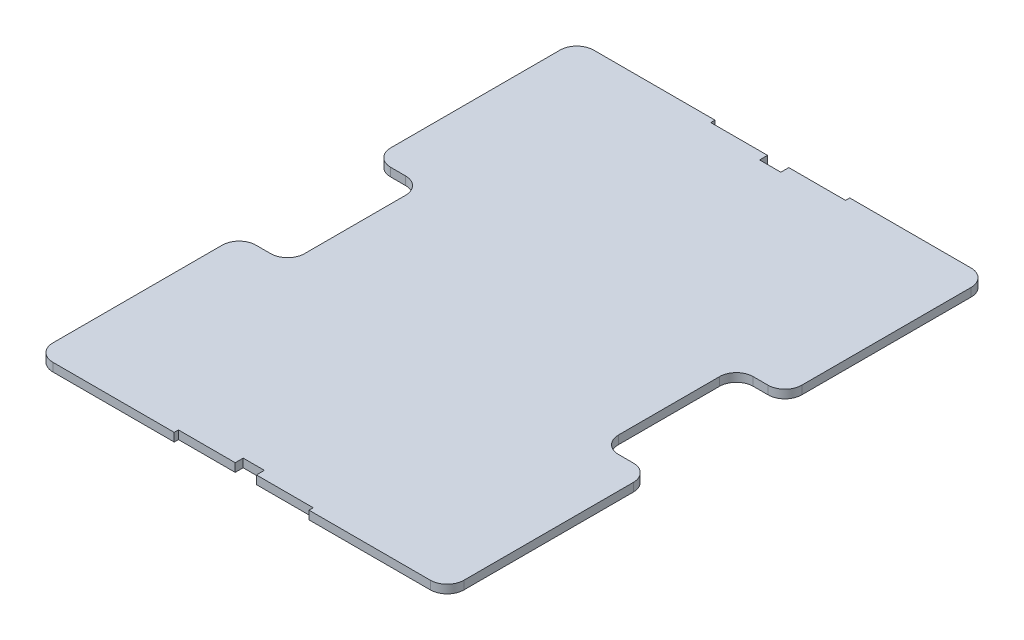
from build123d import *

# Parameters (mm, degrees)
BOSS_EXTRUDE3_DEPTH = 1.5875
FILLET1_R           = 6.35


with BuildPart() as part:
    # Sketch3 → Boss-Extrude3 (new body, symmetric)
    with BuildSketch(Plane(origin=(0, 0, 0), x_dir=(1, 0, 0), z_dir=(0, 1, 0))):
        Polygon((-77.47, -25.4), (-77.47, -101.9175), (-25.4, -101.9175), (-25.4, -100.33), (-4, -100.33), (-4, -97.33), (4, -97.33), (4, -100.33), (25.4, -100.33), (25.4, -101.9175), (77.47, -101.9175), (77.47, -25.4), (59.182, -25.4), (59.182, 25.4), (77.47, 25.4), (77.47, 101.9175), (25.4, 101.9175), (25.4, 100.33), (4, 100.33), (4, 97.33), (-4, 97.33), (-4, 100.33), (-25.4, 100.33), (-25.4, 101.9175), (-77.47, 101.9175), (-77.47, 25.4), (-59.182, 25.4), (-59.182, -25.4), align=None)
    extrude(amount=BOSS_EXTRUDE3_DEPTH, both=True)

    # Fillet1
    fillet1_edges = [part.edges().sort_by_distance(p)[0] for p in [
        (-77.47, 0, -101.9175),
        (77.47, 0, -101.9175),
        (77.47, 0, -25.4),
        (59.182, 0, -25.4),
        (59.182, 0, 25.4),
        (77.47, 0, 25.4),
        (77.47, 0, 101.9175),
        (-77.47, 0, 101.9175),
        (-77.47, 0, 25.4),
        (-59.182, 0, 25.4),
        (-59.182, 0, -25.4),
        (-77.47, 0, -25.4),
    ]]
    fillet(fillet1_edges, radius=FILLET1_R)


solid = part.part
